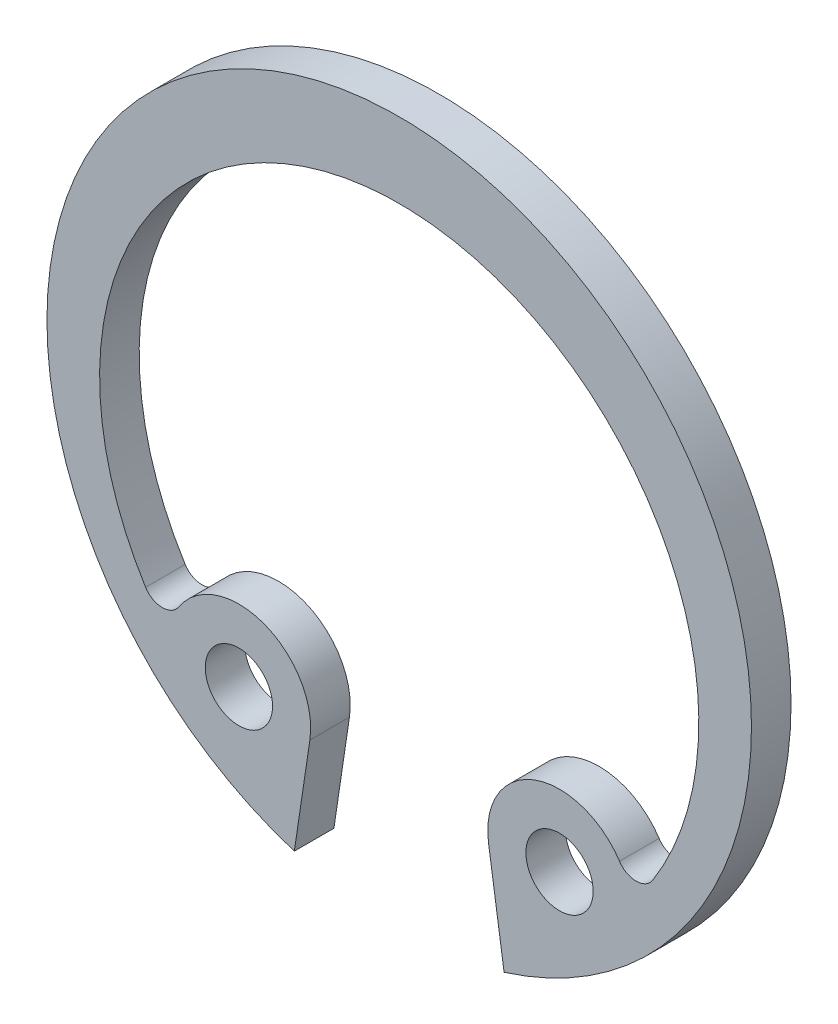
from build123d import *

# Parameters (mm, degrees)
SKETCH1_R           = 0.85
BOSS_EXTRUDE1_DEPTH = 1


with BuildPart() as part:
    # Sketch1 → Boss-Extrude1 (new body)
    with BuildSketch(Plane.XY):
        with BuildLine():
            Line((-2.257442204, -5.86965719), (-2.65, -8.496322734))
            ThreePointArc((-2.65, -8.496322734), (0, 8.9), (2.65, -8.496322734))
            Line((2.65, -8.496322734), (2.257442204, -5.86965719))
            ThreePointArc((2.257442204, -5.86965719), (3.404490458, -3.908136939), (5.56612419, -4.608580375))
            ThreePointArc((5.56612419, -4.608580375), (5.988976647, -4.834574135), (6.407596147, -4.600832621))
            ThreePointArc((6.407596147, -4.600832621), (0, 7), (-6.407596147, -4.600832621))
            ThreePointArc((-6.407596147, -4.600832621), (-5.988976647, -4.834574135), (-5.56612419, -4.608580375))
            ThreePointArc((-5.56612419, -4.608580375), (-3.404490458, -3.908136939), (-2.257442204, -5.86965719))
        make_face()
        with Locations((-4.05, -5.601757633)):
            Circle(SKETCH1_R, mode=Mode.SUBTRACT)
        with Locations((4.05, -5.601757633)):
            Circle(SKETCH1_R, mode=Mode.SUBTRACT)
    extrude(amount=BOSS_EXTRUDE1_DEPTH)


solid = part.part
